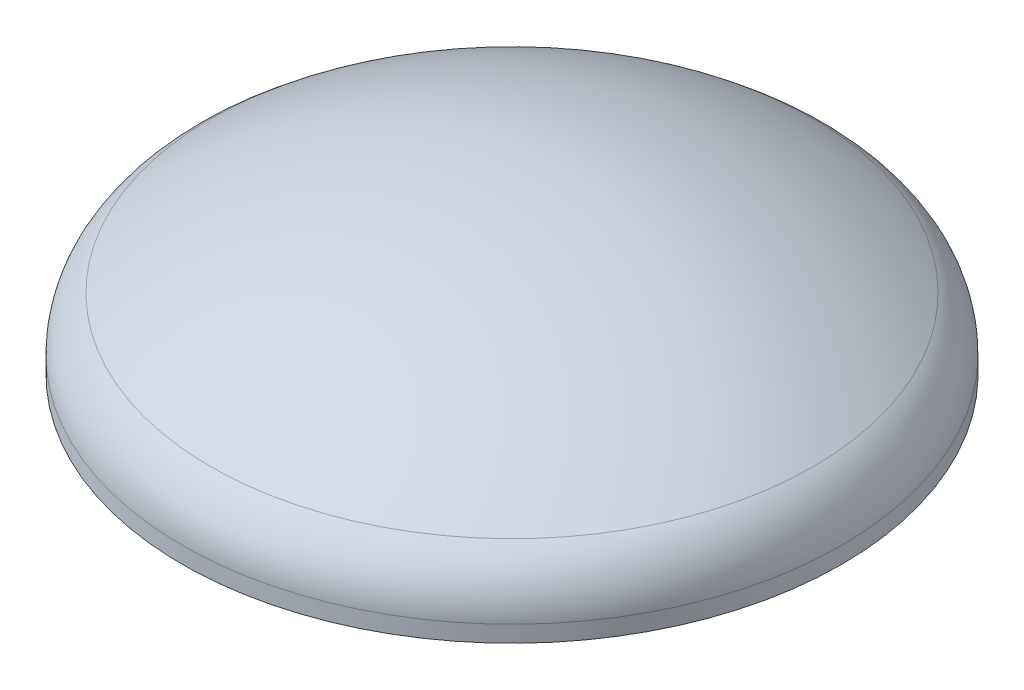
from build123d import *


with BuildPart() as part:
    # Sketch1 → Revolve1 (revolve)
    with BuildSketch(Plane.XY):
        with BuildLine():
            Line((508, 25.4), (508, 0))
            Line((508, 0), (482.6, 0))
            Line((482.6, 0), (482.6, 25.4))
            ThreePointArc((482.6, 25.4), (473.944080845, 60.673745801), (449.942857143, 87.933667667))
            ThreePointArc((449.942857143, 87.933667667), (235.791918316, 193.018653743), (0, 229.152435112))
            Line((0, 229.152435112), (0, 254.552435112))
            ThreePointArc((0, 254.552435112), (243.398109229, 217.253047893), (464.457142857, 108.778223555))
            ThreePointArc((464.457142857, 108.778223555), (496.458774459, 72.431661068), (508, 25.4))
        make_face()
    revolve(axis=Axis((0, 254.552435112, 0), (0, -1, 0)))


solid = part.part
